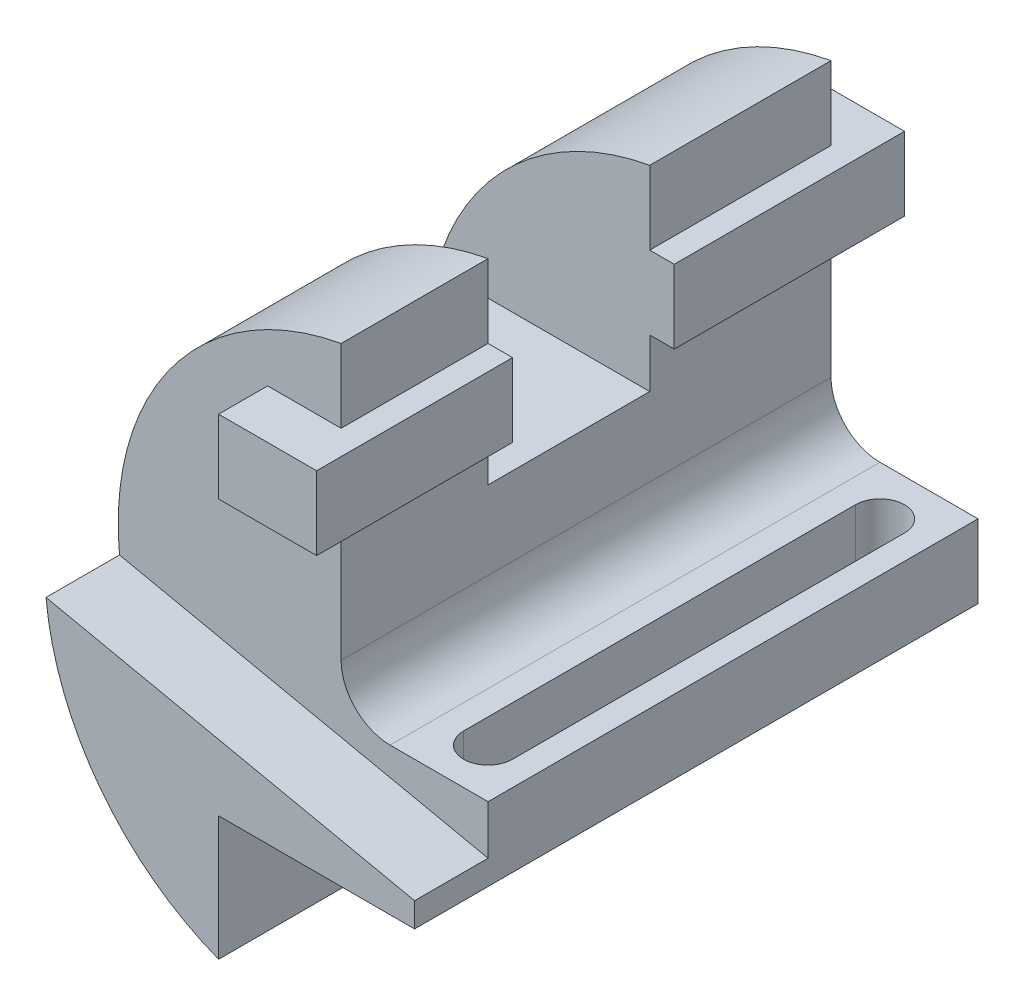
from build123d import *

# Parameters (mm, degrees)
BOSS_EXTRUDE1_DEPTH = 100
SKETCH2_W           = 33
SKETCH2_H           = 40
CUT_EXTRUDE1_DEPTH  = 46.5
SKETCH3_W           = 20
SKETCH3_H           = 15
BOSS_EXTRUDE2_DEPTH = 47
SKETCH5_W           = 20
SKETCH5_H           = 15
BOSS_EXTRUDE3_DEPTH = 40
CUT_EXTRUDE2_REACH  = 42.363
BOSS_EXTRUDE4_DEPTH = 15


with BuildPart() as part:
    # Sketch1 → Boss-Extrude1 (new body)
    with BuildSketch(Plane.XY):
        with BuildLine():
            Line((-10, 54.591666031), (-10, -1.408333969))
            ThreePointArc((-10, -1.408333969), (-7.071067812, -8.479401781), (0, -11.408333969))
            Line((0, -11.408333969), (20, -11.408333969))
            Line((20, -11.408333969), (20, -26.408333969))
            Line((20, -26.408333969), (-20, -26.408333969))
            Line((-20, -26.408333969), (-20, -51.771130952))
            ThreePointArc((-20, -51.771130952), (-55.256322222, 5.195079839), (-10, 54.591666031))
        make_face()
    extrude(amount=BOSS_EXTRUDE1_DEPTH)

    # Sketch2 → Cut-Extrude1 (cut, through all)
    with BuildSketch(Plane(origin=(-10, 0, 0), x_dir=(0, 0, -1), z_dir=(1, 0, 0))):
        with Locations((-53.5, 34.591666031)):
            Rectangle(SKETCH2_W, SKETCH2_H)
    extrude(amount=-CUT_EXTRUDE1_DEPTH, mode=Mode.SUBTRACT)

    # Sketch3 → Boss-Extrude2 (add)
    with BuildSketch(Plane.XY.offset(37)):
        with Locations((-15, 32.091666031)):
            Rectangle(SKETCH3_W, SKETCH3_H)
    extrude(amount=-BOSS_EXTRUDE2_DEPTH)

    # Sketch5 → Boss-Extrude3 (add)
    with BuildSketch(Plane(origin=(0, 0, 70), x_dir=(-1, 0, 0), z_dir=(0, 0, -1))):
        with Locations((15, 32.091666031)):
            Rectangle(SKETCH5_W, SKETCH5_H)
    extrude(amount=-BOSS_EXTRUDE3_DEPTH)

    # Sketch6 → Cut-Extrude2 (cut, up to next)
    with BuildSketch(Plane(origin=(0, -11.408333969, 0), x_dir=(1, 0, 0), z_dir=(0, 1, 0)), mode=Mode.PRIVATE) as cut_extrude2_sk1:
        with BuildLine():
            Line((15, -10), (15, -90))
            ThreePointArc((15, -90), (10, -95), (5, -90))
            Line((5, -90), (5, -10))
            ThreePointArc((5, -10), (10, -5), (15, -10))
        make_face()
    cut_extrude2_tool1 = extrude(cut_extrude2_sk1.sketch, amount=-CUT_EXTRUDE2_REACH, mode=Mode.PRIVATE) & part.part
    add(cut_extrude2_tool1.solids().sort_by_distance((10, -11.408334, 50))[0], mode=Mode.SUBTRACT)

    # Sketch7 → Boss-Extrude4 (add)
    with BuildSketch(Plane.XY.offset(100)):
        with BuildLine():
            Line((20, -21.408333969), (-55.235044142, -5.416631669))
            ThreePointArc((-55.235044142, -5.416631669), (-44.184418834, -33.585519682), (-20, -51.771130952))
            Line((-20, -51.771130952), (-20, -26.408333969))
            Line((-20, -26.408333969), (20, -26.408333969))
            Line((20, -26.408333969), (20, -21.408333969))
        make_face()
    extrude(amount=BOSS_EXTRUDE4_DEPTH)


solid = part.part
